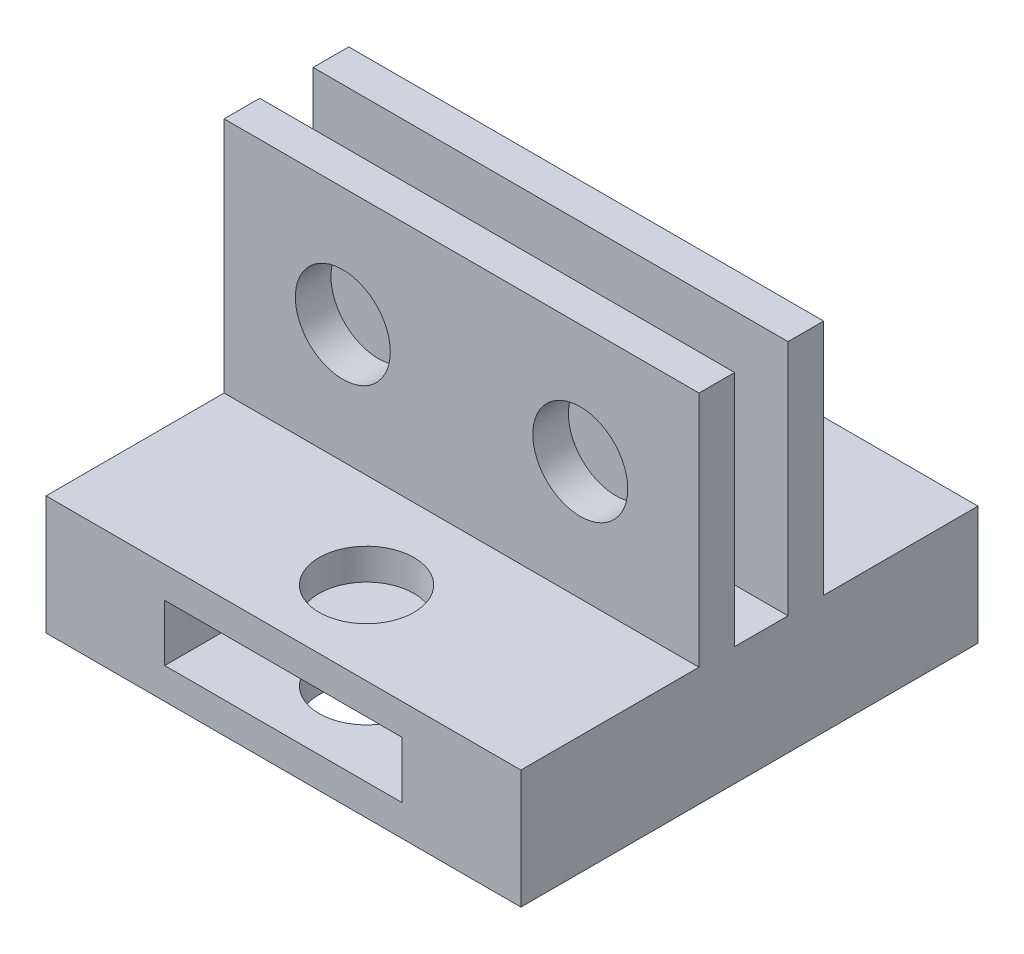
from build123d import *

# Parameters (mm, degrees)
SKETCH1_W                = 40
SKETCH1_H                = 30
SKETCH1_R                = 4
SKETCH1_W_2              = 20
SKETCH1_H_2              = 4.76
BOSS_EXTRUDE1_DEPTH      = 3
BOSS_EXTRUDE3_START      = -7.5
SKETCH1_5_W              = 40
SKETCH1_5_H              = 30
SKETCH1_5_R              = 4
SKETCH1_5_W_2            = 20
SKETCH1_5_H_2            = 4.76
BOSS_EXTRUDE3_DEPTH      = 7.5
CUT_EXTRUDE1_START       = -4.5
SKETCH1_6_W              = 40
SKETCH1_6_H              = 20
SKETCH1_6_R              = 4
CUT_EXTRUDE1_DEPTH       = 4.5
BOSS_EXTRUDE4_DEPTH      = 18
BOSS_EXTRUDE4_DEPTH_BACK = 20.5
SKETCH1_7_W              = 40
SKETCH1_7_H              = 10
SKETCH1_7_W_2            = 20
SKETCH1_7_H_2            = 4.76
SKETCH5_R                = 4
CUT_EXTRUDE2_DEPTH       = 10


with BuildPart() as part:
    # Sketch1 → Boss-Extrude1 (new body)
    with BuildSketch(Plane.XY):
        with Locations((-26.342010442, -115)):
            Rectangle(SKETCH1_W, SKETCH1_H)
        with Locations((-36.342010442, -110)):
            Circle(SKETCH1_R, mode=Mode.SUBTRACT)
        with Locations((-16.342010442, -110)):
            Circle(SKETCH1_R, mode=Mode.SUBTRACT)
        with Locations((-26.342010442, -125)):
            Rectangle(SKETCH1_W_2, SKETCH1_H_2, mode=Mode.SUBTRACT)
    extrude(amount=BOSS_EXTRUDE1_DEPTH)

    # Sketch1_5 → Boss-Extrude3 (add)
    with BuildSketch(Plane.XY.offset(BOSS_EXTRUDE3_START)):
        with Locations((-26.342010442, -115)):
            Rectangle(SKETCH1_5_W, SKETCH1_5_H)
        with Locations((-36.342010442, -110)):
            Circle(SKETCH1_5_R, mode=Mode.SUBTRACT)
        with Locations((-16.342010442, -110)):
            Circle(SKETCH1_5_R, mode=Mode.SUBTRACT)
        with Locations((-26.342010442, -125)):
            Rectangle(SKETCH1_5_W_2, SKETCH1_5_H_2, mode=Mode.SUBTRACT)
    extrude(amount=BOSS_EXTRUDE3_DEPTH)

    # Sketch1_6 → Cut-Extrude1 (cut)
    with BuildSketch(Plane.XY.offset(CUT_EXTRUDE1_START)):
        with Locations((-26.342010442, -110)):
            Rectangle(SKETCH1_6_W, SKETCH1_6_H)
        with Locations((-36.342010442, -110)):
            Circle(SKETCH1_6_R, mode=Mode.SUBTRACT)
        with Locations((-16.342010442, -110)):
            Circle(SKETCH1_6_R, mode=Mode.SUBTRACT)
    extrude(amount=CUT_EXTRUDE1_DEPTH, mode=Mode.SUBTRACT)

    # Sketch1_7 → Boss-Extrude4 (add, two sides: drawn at the far end of the back side and taken through both)
    with BuildSketch(Plane.XY.offset(-BOSS_EXTRUDE4_DEPTH_BACK)):
        with Locations((-26.342010442, -125)):
            Rectangle(SKETCH1_7_W, SKETCH1_7_H)
        with Locations((-26.342010442, -125)):
            Rectangle(SKETCH1_7_W_2, SKETCH1_7_H_2, mode=Mode.SUBTRACT)
    extrude(amount=BOSS_EXTRUDE4_DEPTH + BOSS_EXTRUDE4_DEPTH_BACK)

    # Sketch5 → Cut-Extrude2 (cut)
    with BuildSketch(Plane.XZ.offset(130)):
        with Locations((-26.342010442, 11)):
            Circle(SKETCH5_R)
        with Locations((-26.342010442, -13.5)):
            Circle(SKETCH5_R)
    extrude(amount=-CUT_EXTRUDE2_DEPTH, mode=Mode.SUBTRACT)


solid = part.part
